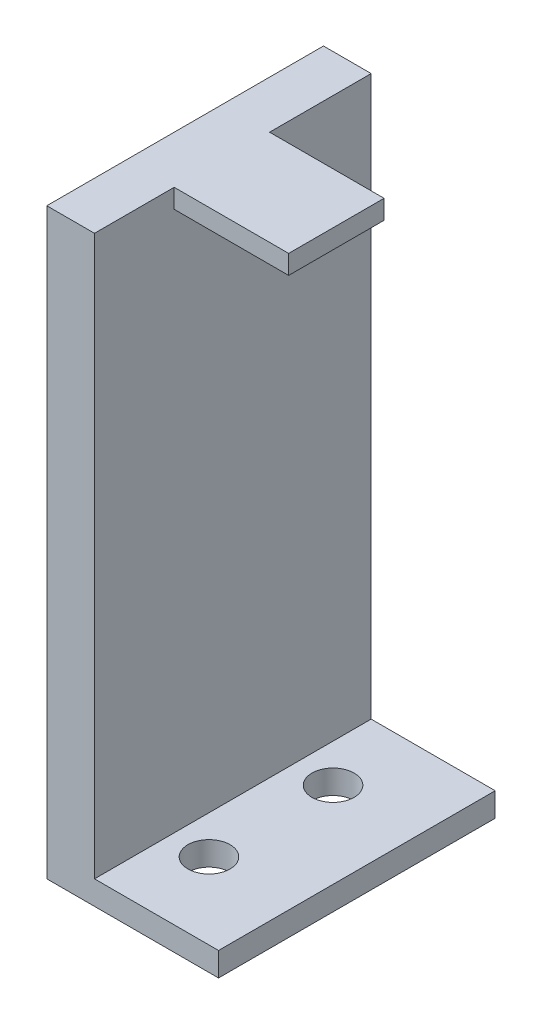
from build123d import *

# Parameters (mm, degrees)
SKETCH1_W                      = 22.86
SKETCH1_H                      = 36.83
BOSS_EXTRUDE1_DEPTH            = 3.175
SKETCH3_W                      = 6.35
SKETCH3_H                      = 36.83
BOSS_EXTRUDE2_DEPTH            = 74.422
SKETCH4_W                      = 12.7
SKETCH4_H                      = 2.54
BOSS_EXTRUDE3_DEPTH            = 15.24
F_2_0_221_DIAMETER_HOLE1_D     = 5.6134
F_2_0_221_DIAMETER_HOLE1_DEPTH = 3.175


with BuildPart() as part:
    # Sketch1 → Boss-Extrude1 (new body)
    with BuildSketch(Plane(origin=(0, 0, 0), x_dir=(1, 0, 0), z_dir=(0, 1, 0))):
        with Locations((-11.43, 18.415)):
            Rectangle(SKETCH1_W, SKETCH1_H)
    extrude(amount=BOSS_EXTRUDE1_DEPTH)

    # Sketch3 → Boss-Extrude2 (add)
    with BuildSketch(Plane(origin=(0, 3.175, 0), x_dir=(1, 0, 0), z_dir=(0, 1, 0))):
        with Locations((-19.685, 18.415)):
            Rectangle(SKETCH3_W, SKETCH3_H)
    extrude(amount=BOSS_EXTRUDE2_DEPTH)

    # Sketch4 → Boss-Extrude3 (add)
    with BuildSketch(Plane(origin=(-16.51, 0, 0), x_dir=(0, 0, -1), z_dir=(1, 0, 0))):
        with Locations((16.956564639, 76.327)):
            Rectangle(SKETCH4_W, SKETCH4_H)
    extrude(amount=BOSS_EXTRUDE3_DEPTH)

    # #2 (0.221) Diameter Hole1
    with Locations(Plane(origin=(0, 0, 0), x_dir=(-1, 0, 0), z_dir=(0, -1, 0))):
        with Locations((11.43, 10.16), (11.43, 26.67)):
            Hole(F_2_0_221_DIAMETER_HOLE1_D / 2, depth=F_2_0_221_DIAMETER_HOLE1_DEPTH)


solid = part.part
